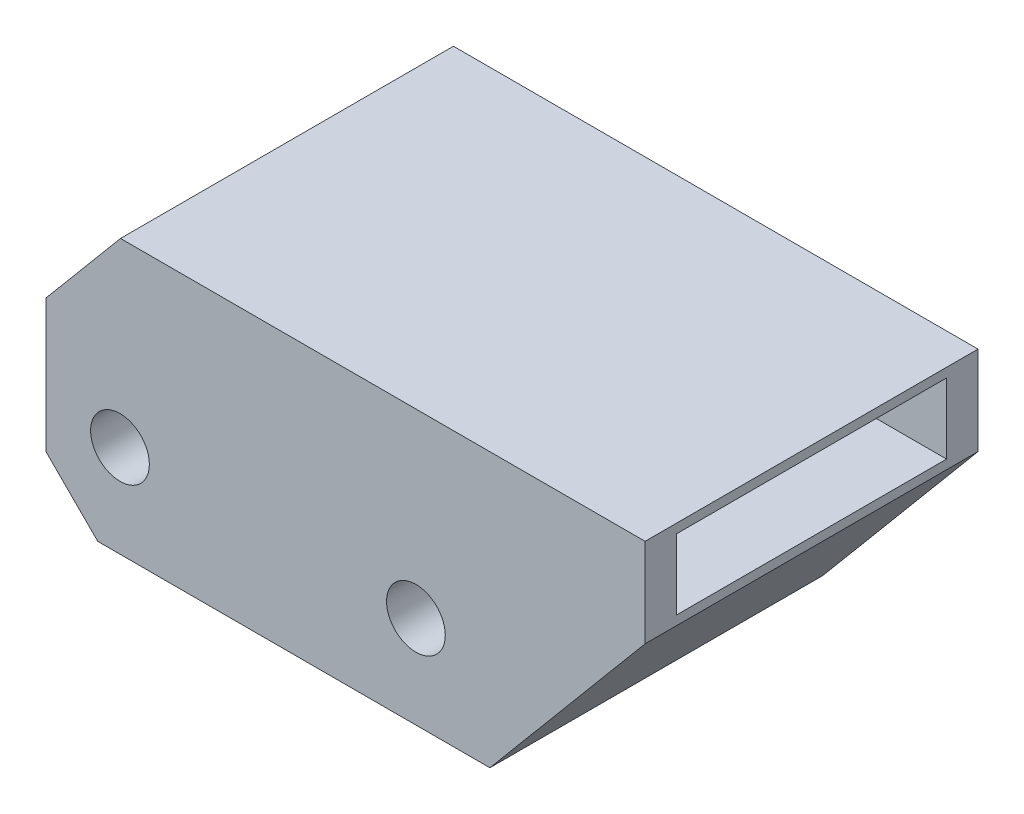
from build123d import *

# Parameters (mm, degrees)
ESBO_O1_R                = 3.97
RESSALTO_EXTRUS_O1_DEPTH = 22.5
ESBO_O2_W                = 36.5
ESBO_O2_H                = 9.5
CORTE_EXTRUS_O1_DEPTH    = 25
CHANFRO1_SIZE            = 7


with BuildPart() as part:
    # Esboço1 → Ressalto-extrusão1 (new body, symmetric)
    with BuildSketch(Plane.XY):
        Polygon((30, -12.5), (-30, -12.5), (-30, 12.5), (-19.930804426, 24.5), (30.977490779, 24.5), (50.977490779, 24.5), (50.977490779, 12.5), align=None)
        with Locations((-20, 0)):
            Circle(ESBO_O1_R, mode=Mode.SUBTRACT)
        with Locations((20, 0)):
            Circle(ESBO_O1_R, mode=Mode.SUBTRACT)
    extrude(amount=RESSALTO_EXTRUS_O1_DEPTH, both=True)

    # Esboço2 → Corte-extrusão1 (cut)
    with BuildSketch(Plane(origin=(50.977490779, 0, 0), x_dir=(0, 0, -1), z_dir=(1, 0, 0))):
        with Locations((0, 18.5)):
            Rectangle(ESBO_O2_W, ESBO_O2_H)
    extrude(amount=-CORTE_EXTRUS_O1_DEPTH, mode=Mode.SUBTRACT)

    # Chanfro1
    chanfro1_edges = [part.edges().sort_by_distance(p)[0] for p in [
        (-30, -12.5, 0),
    ]]
    chamfer(chanfro1_edges, length=CHANFRO1_SIZE)


solid = part.part
